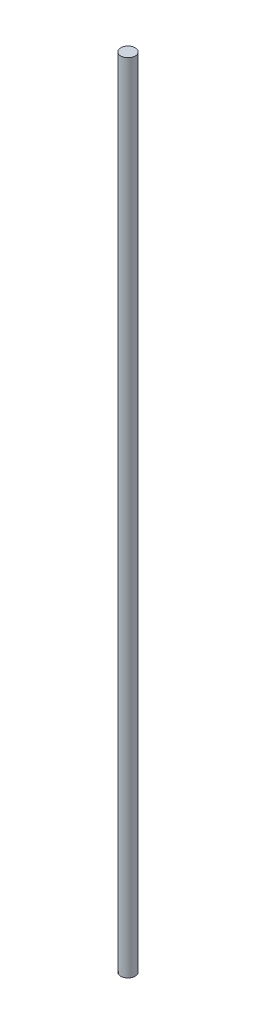
from build123d import *

# Parameters (mm, degrees)
ESBO_O1_R                = 4
RESSALTO_EXTRUS_O1_DEPTH = 221.5


with BuildPart() as part:
    # Esboço1 → Ressalto-extrusão1 (new body, symmetric)
    with BuildSketch(Plane(origin=(0, 0, 0), x_dir=(1, 0, 0), z_dir=(0, 1, 0))):
        Circle(ESBO_O1_R)
    extrude(amount=RESSALTO_EXTRUS_O1_DEPTH, both=True)


solid = part.part
